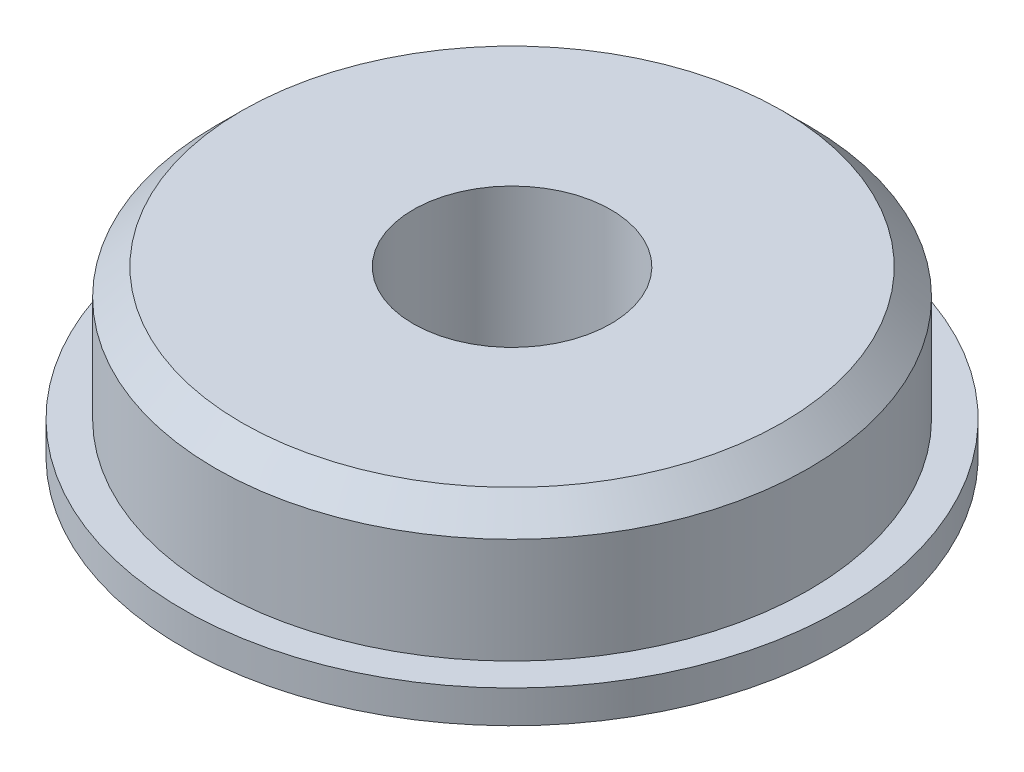
from build123d import *

# Parameters (mm, degrees)
SKETCH1_R           = 14.2875
SKETCH1_R_2         = 4.7625
BOSS_EXTRUDE1_DEPTH = 7.9248
SKETCH2_R           = 15.875
SKETCH2_R_2         = 14.2875
BOSS_EXTRUDE2_DEPTH = 1.5748
CHAMFER1_SIZE       = 1.27


with BuildPart() as part:
    # Sketch1 → Boss-Extrude1 (new body)
    with BuildSketch(Plane(origin=(0, 0, 0), x_dir=(1, 0, 0), z_dir=(0, 1, 0))):
        Circle(SKETCH1_R)
        Circle(SKETCH1_R_2, mode=Mode.SUBTRACT)
    extrude(amount=BOSS_EXTRUDE1_DEPTH)

    # Sketch2 → Boss-Extrude2 (add)
    with BuildSketch(Plane.XZ):
        Circle(SKETCH2_R)
        Circle(SKETCH2_R_2, mode=Mode.SUBTRACT)
    extrude(amount=-BOSS_EXTRUDE2_DEPTH)

    # Chamfer1
    chamfer1_edges = [part.edges().sort_by_distance(p)[0] for p in [
        (-14.2875, 7.9248, 0),
    ]]
    chamfer(chamfer1_edges, length=CHAMFER1_SIZE)


solid = part.part
